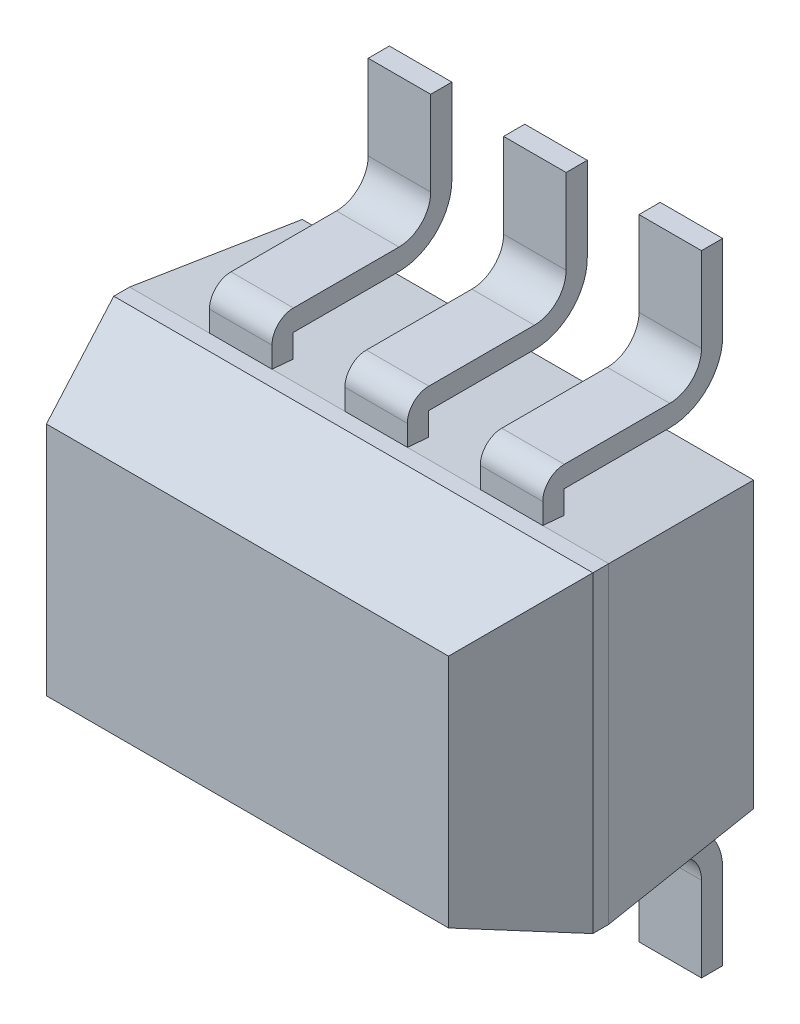
from build123d import *

# Parameters (mm, degrees)
SKETCH1_W                = 2.3
SKETCH1_H                = 1.5
BASE_EXTRUDE_DEPTH       = 1.3462
CHAMFER1_SIZE            = 0.508
CHAMFER1_SIZE2           = 0.184896879
CHAMFER1_PART_2_SIZE     = 0.508
CHAMFER1_PART_2_SIZE2    = 0.184896879
CHAMFER1_PART_3_SIZE     = 0.508
CHAMFER1_PART_3_SIZE2    = 0.184896879
CHAMFER1_PART_4_SIZE     = 0.508
CHAMFER1_PART_4_SIZE2    = 0.184896879
CHAMFER2_SIZE            = 0.762
CHAMFER2_SIZE2           = 0.066666362
CHAMFER2_PART_2_SIZE     = 0.762
CHAMFER2_PART_2_SIZE2    = 0.066666362
CHAMFER2_PART_3_SIZE     = 0.762
CHAMFER2_PART_3_SIZE2    = 0.066666362
CHAMFER2_PART_4_SIZE     = 0.762
CHAMFER2_PART_4_SIZE2    = 0.066666362
SKETCH3_R                = 0.15
CUT_EXTRUDE1_DEPTH       = 0.127
BOSS_EXTRUDE_THIN3_DEPTH = 0.15
LPATTERN1_COUNT          = 3
LPATTERN1_PITCH          = 0.65
MIRROR1_COPY_1_DEPTH     = 0.15
MIRROR1_COPY_2_DEPTH     = 0.15


with BuildPart() as part:
    # Sketch1 → Base-Extrude (new body)
    with BuildSketch(Plane.XY):
        with Locations((3.200498433, 1.512)):
            Rectangle(SKETCH1_W, SKETCH1_H)
    extrude(amount=BASE_EXTRUDE_DEPTH)

    # Chamfer1
    chamfer1_edges = [part.edges().sort_by_distance(p)[0] for p in [
        (4.350498433, 1.512, 1.3462),
    ]]
    chamfer1_side = [part.faces().sort_by_distance(p)[0] for p in [
        (4.350498433, 1.512, 0.6731),
    ]]
    chamfer(chamfer1_edges, length=CHAMFER1_SIZE, length2=CHAMFER1_SIZE2, reference=chamfer1_side[0])

    # Chamfer1 part 2
    chamfer1_part_2_edges = [part.edges().sort_by_distance(p)[0] for p in [
        (3.200498433, 2.262, 1.3462),
    ]]
    chamfer1_part_2_side = [part.faces().sort_by_distance(p)[0] for p in [
        (3.200498433, 2.262, 0.6731),
    ]]
    chamfer(chamfer1_part_2_edges, length=CHAMFER1_PART_2_SIZE, length2=CHAMFER1_PART_2_SIZE2, reference=chamfer1_part_2_side[0])

    # Chamfer1 part 3
    chamfer1_part_3_edges = [part.edges().sort_by_distance(p)[0] for p in [
        (2.050498433, 1.512, 1.3462),
    ]]
    chamfer1_part_3_side = [part.faces().sort_by_distance(p)[0] for p in [
        (2.050498433, 1.512, 0.6731),
    ]]
    chamfer(chamfer1_part_3_edges, length=CHAMFER1_PART_3_SIZE, length2=CHAMFER1_PART_3_SIZE2, reference=chamfer1_part_3_side[0])

    # Chamfer1 part 4
    chamfer1_part_4_edges = [part.edges().sort_by_distance(p)[0] for p in [
        (3.200498433, 0.762, 1.3462),
    ]]
    chamfer1_part_4_side = [part.faces().sort_by_distance(p)[0] for p in [
        (3.200498433, 0.762, 0.6731),
    ]]
    chamfer(chamfer1_part_4_edges, length=CHAMFER1_PART_4_SIZE, length2=CHAMFER1_PART_4_SIZE2, reference=chamfer1_part_4_side[0])

    # Chamfer2
    chamfer2_edges = [part.edges().sort_by_distance(p)[0] for p in [
        (3.200498433, 2.262, 0),
    ]]
    chamfer2_side = [part.faces().sort_by_distance(p)[0] for p in [
        (3.200498433, 2.262, 0.4191),
    ]]
    chamfer(chamfer2_edges, length=CHAMFER2_SIZE, length2=CHAMFER2_SIZE2, reference=chamfer2_side[0])

    # Chamfer2 part 2
    chamfer2_part_2_edges = [part.edges().sort_by_distance(p)[0] for p in [
        (4.350498433, 1.512, 0),
    ]]
    chamfer2_part_2_side = [part.faces().sort_by_distance(p)[0] for p in [
        (4.350498433, 1.512, 0.4191),
    ]]
    chamfer(chamfer2_part_2_edges, length=CHAMFER2_PART_2_SIZE, length2=CHAMFER2_PART_2_SIZE2, reference=chamfer2_part_2_side[0])

    # Chamfer2 part 3
    chamfer2_part_3_edges = [part.edges().sort_by_distance(p)[0] for p in [
        (3.200498433, 0.762, 0),
    ]]
    chamfer2_part_3_side = [part.faces().sort_by_distance(p)[0] for p in [
        (3.200498433, 0.762, 0.4191),
    ]]
    chamfer(chamfer2_part_3_edges, length=CHAMFER2_PART_3_SIZE, length2=CHAMFER2_PART_3_SIZE2, reference=chamfer2_part_3_side[0])

    # Chamfer2 part 4
    chamfer2_part_4_edges = [part.edges().sort_by_distance(p)[0] for p in [
        (2.050498433, 1.512, 0),
    ]]
    chamfer2_part_4_side = [part.faces().sort_by_distance(p)[0] for p in [
        (2.050498433, 1.512, 0.4191),
    ]]
    chamfer(chamfer2_part_4_edges, length=CHAMFER2_PART_4_SIZE, length2=CHAMFER2_PART_4_SIZE2, reference=chamfer2_part_4_side[0])

    # Sketch3 → Cut-Extrude1 (cut)
    with BuildSketch(Plane(origin=(0.118935742, 0.142956615, 1.3462), x_dir=(1, 0, 0), z_dir=(0, 0, 1))):
        with Locations((1.946665812, 1.27)):
            Circle(SKETCH3_R)
    extrude(amount=-CUT_EXTRUDE1_DEPTH, mode=Mode.SUBTRACT)

    # Sketch4 → Boss-Extrude-Thin3 (add, symmetric)
    with BuildSketch(Plane(origin=(2.583898433, 0, 0), x_dir=(0, 0, -1), z_dir=(1, 0, 0))):
        with BuildLine():
            Line((0, 0), (0, 0.4064))
            ThreePointArc((0, 0.4064), (-0.044636927, 0.514163073), (-0.1524, 0.5588))
            Line((-0.1524, 0.5588), (-0.6588, 0.5588))
            ThreePointArc((-0.6588, 0.5588), (-0.73177342, 0.58902658), (-0.762, 0.662))
            Line((-0.762, 0.662), (-0.762, 1.062))
            Line((-0.762, 1.062), (-0.6604, 1.062))
            Line((-0.6604, 1.062), (-0.6604, 0.662))
            ThreePointArc((-0.6604, 0.662), (-0.659931371, 0.660868629), (-0.6588, 0.6604))
            Line((-0.6588, 0.6604), (-0.1524, 0.6604))
            ThreePointArc((-0.1524, 0.6604), (0.027205122, 0.586005122), (0.1016, 0.4064))
            Line((0.1016, 0.4064), (0.1016, 0))
            Line((0.1016, 0), (0, 0))
        make_face()
    boss_extrude_thin3 = extrude(amount=BOSS_EXTRUDE_THIN3_DEPTH, both=True)

    # LPattern1: Boss-Extrude-Thin3 ×3
    with Locations(*[(i * LPATTERN1_PITCH, 0, 0) for i in range(1, LPATTERN1_COUNT)]):
        add(boss_extrude_thin3)

    # Mirror1: Boss-Extrude-Thin3 across plane
    add(boss_extrude_thin3.mirror(Plane.ZX.offset(1.512)))

    # Mirror1 copy 1 sketch → Mirror1 copy 1 (add, symmetric)
    with BuildSketch(Plane(origin=(3.233898433, 3.024, 0), x_dir=(0, 0, -1), z_dir=(1, 0, 0))):
        with BuildLine():
            Line((0, 0), (0, -0.4064))
            ThreePointArc((0, -0.4064), (-0.044636927, -0.514163073), (-0.1524, -0.5588))
            Line((-0.1524, -0.5588), (-0.6588, -0.5588))
            ThreePointArc((-0.6588, -0.5588), (-0.73177342, -0.58902658), (-0.762, -0.662))
            Line((-0.762, -0.662), (-0.762, -1.062))
            Line((-0.762, -1.062), (-0.6604, -1.062))
            Line((-0.6604, -1.062), (-0.6604, -0.662))
            ThreePointArc((-0.6604, -0.662), (-0.659931371, -0.660868629), (-0.6588, -0.6604))
            Line((-0.6588, -0.6604), (-0.1524, -0.6604))
            ThreePointArc((-0.1524, -0.6604), (0.027205122, -0.586005122), (0.1016, -0.4064))
            Line((0.1016, -0.4064), (0.1016, 0))
            Line((0.1016, 0), (0, 0))
        make_face()
    extrude(amount=MIRROR1_COPY_1_DEPTH, both=True)

    # Mirror1 copy 2 sketch → Mirror1 copy 2 (add, symmetric)
    with BuildSketch(Plane(origin=(3.883898433, 3.024, 0), x_dir=(0, 0, -1), z_dir=(1, 0, 0))):
        with BuildLine():
            Line((0, 0), (0, -0.4064))
            ThreePointArc((0, -0.4064), (-0.044636927, -0.514163073), (-0.1524, -0.5588))
            Line((-0.1524, -0.5588), (-0.6588, -0.5588))
            ThreePointArc((-0.6588, -0.5588), (-0.73177342, -0.58902658), (-0.762, -0.662))
            Line((-0.762, -0.662), (-0.762, -1.062))
            Line((-0.762, -1.062), (-0.6604, -1.062))
            Line((-0.6604, -1.062), (-0.6604, -0.662))
            ThreePointArc((-0.6604, -0.662), (-0.659931371, -0.660868629), (-0.6588, -0.6604))
            Line((-0.6588, -0.6604), (-0.1524, -0.6604))
            ThreePointArc((-0.1524, -0.6604), (0.027205122, -0.586005122), (0.1016, -0.4064))
            Line((0.1016, -0.4064), (0.1016, 0))
            Line((0.1016, 0), (0, 0))
        make_face()
    extrude(amount=MIRROR1_COPY_2_DEPTH, both=True)


solid = part.part
